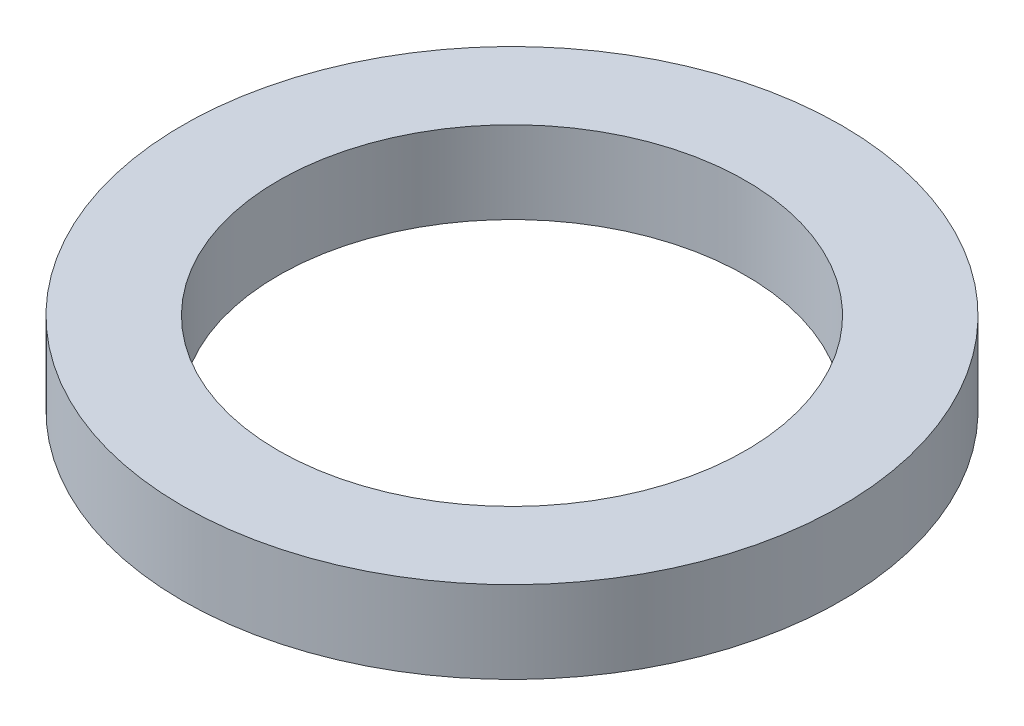
from build123d import *

# Parameters (mm, degrees)
SKETCH1_W = 11.1125
SKETCH1_H = 9.525


with BuildPart() as part:
    # Sketch1 → Revolve1 (revolve)
    with BuildSketch(Plane.XY):
        with Locations((32.67075, -7.9375)):
            Rectangle(SKETCH1_W, SKETCH1_H)
    revolve(axis=Axis((0, 22.709640493, 0), (0, -1, 0)))


solid = part.part
